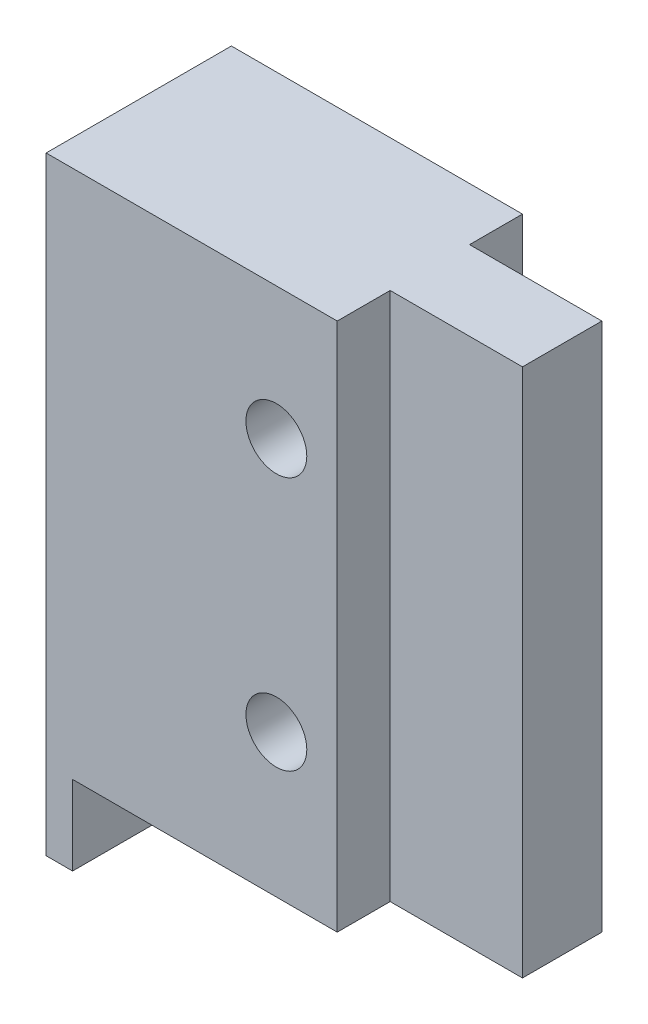
from build123d import *

# Parameters (mm, degrees)
BOSS_EXTRUDE1_DEPTH      = 3.5
BOSS_EXTRUDE1_DEPTH_BACK = 3.5
SKETCH1_R                = 1.15
BOSS_EXTRUDE2_DEPTH      = 1.5
BOSS_EXTRUDE2_DEPTH_BACK = 1.5
SKETCH1_3_W              = 5
SKETCH1_3_H              = 20


with BuildPart() as part:
    # Sketch1 → Boss-Extrude1 (new, two sides: drawn at the far end of the back side and taken through both)
    with BuildSketch(Plane.XY.offset(-BOSS_EXTRUDE1_DEPTH_BACK)):
        Polygon((1, 0), (1, 3), (11, 3), (11, 23), (0, 23), (0, 0), align=None)
        with Locations((8.7, 8.4)):
            Circle(SKETCH1_R, mode=Mode.SUBTRACT)
        with Locations((8.7, 18)):
            Circle(SKETCH1_R, mode=Mode.SUBTRACT)
    extrude(amount=BOSS_EXTRUDE1_DEPTH + BOSS_EXTRUDE1_DEPTH_BACK)

    # Sketch1_3 → Boss-Extrude2 (add, two sides: drawn at the far end of the back side and taken through both)
    with BuildSketch(Plane.XY.offset(-BOSS_EXTRUDE2_DEPTH_BACK)):
        with Locations((13.5, 13)):
            Rectangle(SKETCH1_3_W, SKETCH1_3_H)
    extrude(amount=BOSS_EXTRUDE2_DEPTH + BOSS_EXTRUDE2_DEPTH_BACK)


solid = part.part
